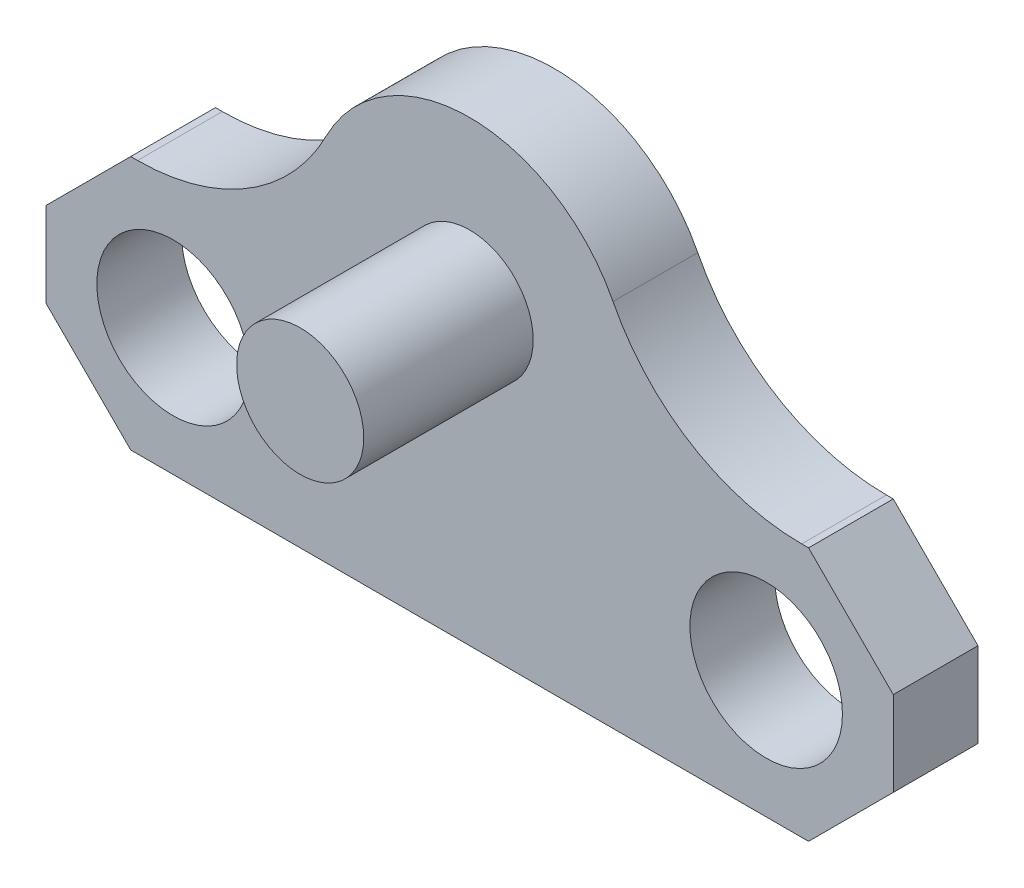
from build123d import *

# Parameters (mm, degrees)
SKETCH1_R           = 2.286
BOSS_EXTRUDE1_DEPTH = 2.54
SKETCH2_R           = 1.905
BOSS_EXTRUDE2_DEPTH = 5.08
CHAMFER1_SIZE       = 2.54


with BuildPart() as part:
    # Sketch1 → Boss-Extrude1 (new body)
    with BuildSketch(Plane.XY):
        with BuildLine():
            Line((22.654726315, 7.62), (25.4, 7.62))
            Line((25.4, 7.62), (25.4, 0))
            Line((25.4, 0), (0, 0))
            Line((0, 0), (0, 7.62))
            Line((0, 7.62), (2.745273685, 7.62))
            ThreePointArc((2.745273685, 7.62), (6.061453031, 8.554701805), (8.401368182, 11.083636364))
            ThreePointArc((8.401368182, 11.083636364), (12.7, 13.716), (16.998631818, 11.083636364))
            ThreePointArc((16.998631818, 11.083636364), (19.338546969, 8.554701805), (22.654726315, 7.62))
        make_face()
        with Locations((3.81, 3.81)):
            Circle(SKETCH1_R, mode=Mode.SUBTRACT)
        with Locations((21.59, 3.81)):
            Circle(SKETCH1_R, mode=Mode.SUBTRACT)
    extrude(amount=BOSS_EXTRUDE1_DEPTH)

    # Sketch2 → Boss-Extrude2 (add)
    with BuildSketch(Plane.XY.offset(2.54)):
        with Locations((12.7, 8.89)):
            Circle(SKETCH2_R)
    extrude(amount=BOSS_EXTRUDE2_DEPTH)

    # Chamfer1
    chamfer1_edges = [part.edges().sort_by_distance(p)[0] for p in [
        (0, 7.62, 1.27),
        (25.4, 7.62, 1.27),
        (25.4, 0, 1.27),
        (0, 0, 1.27),
    ]]
    chamfer(chamfer1_edges, length=CHAMFER1_SIZE)


solid = part.part
